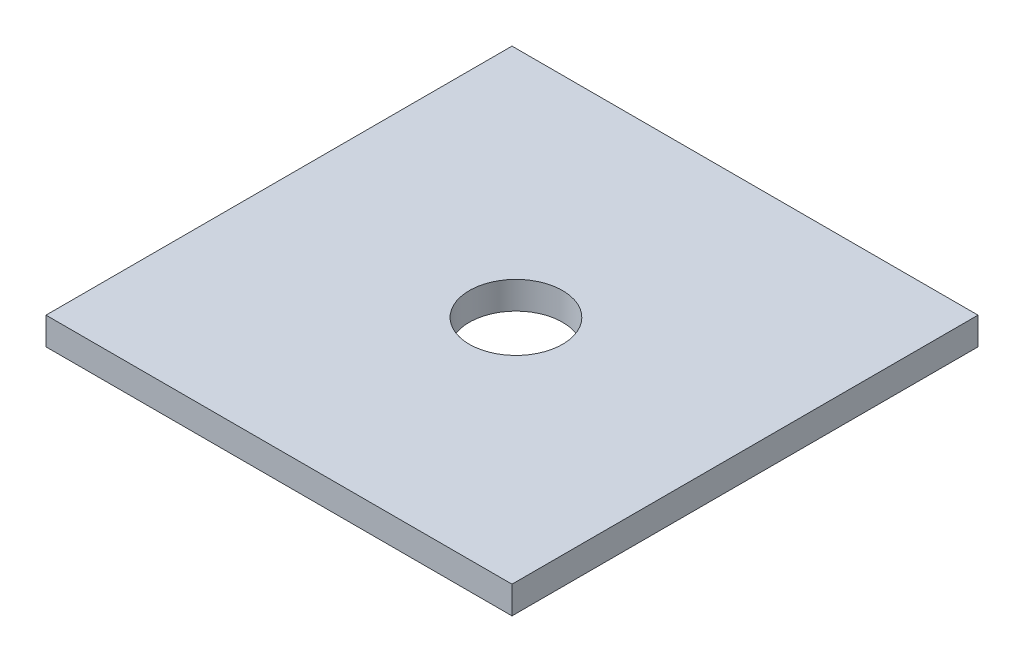
from build123d import *

# Parameters (mm, degrees)
SKETCH1_W           = 50
SKETCH1_H           = 50
BOSS_EXTRUDE1_DEPTH = 2.95
SKETCH2_R           = 5
CUT_EXTRUDE1_DEPTH  = 6.86


with BuildPart() as part:
    # Sketch1 → Boss-Extrude1 (new body)
    with BuildSketch(Plane(origin=(0, 0, 0), x_dir=(1, 0, 0), z_dir=(0, 1, 0))):
        with Locations((-0.423728814, -4.290254237)):
            Rectangle(SKETCH1_W, SKETCH1_H)
    extrude(amount=BOSS_EXTRUDE1_DEPTH)

    # Sketch2 → Cut-Extrude1 (cut)
    with BuildSketch(Plane(origin=(0, 2.95, 0), x_dir=(1, 0, 0), z_dir=(0, 1, 0))):
        with Locations((0, -4.290254237)):
            Circle(SKETCH2_R)
    extrude(amount=-CUT_EXTRUDE1_DEPTH, mode=Mode.SUBTRACT)


solid = part.part
